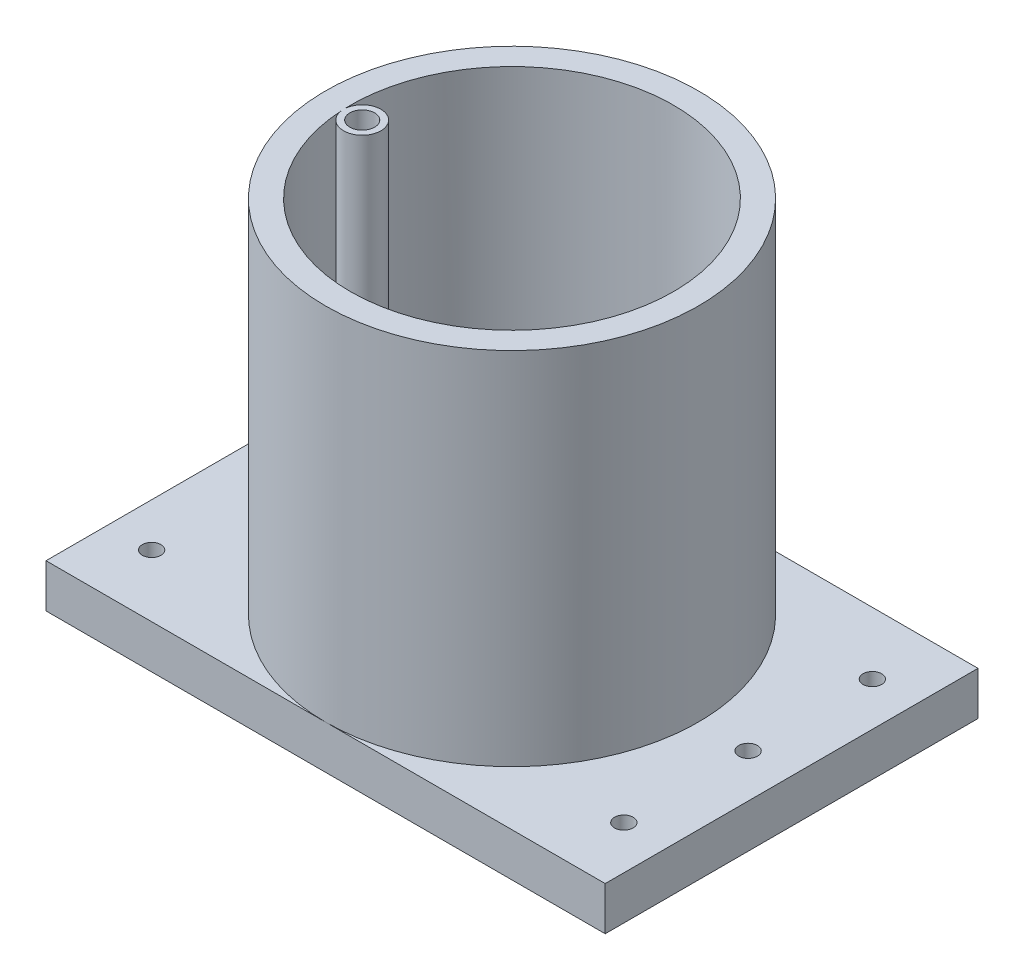
from build123d import *

# Parameters (mm, degrees)
IZIM1_R                     = 30
Y_KSEKLIK_EKSTR_ZYON1_DEPTH = 65
IZIM2_R                     = 26
KES_EKSTR_ZYON1_DEPTH       = 62
Y_KSEKLIK_EKSTR_ZYON4_START = 10
IZIM3_R                     = 3
Y_KSEKLIK_EKSTR_ZYON4_DEPTH = 52
IZIM4_R                     = 2
KES_EKSTR_ZYON2_DEPTH       = 52
IZIM5_W                     = 90
IZIM5_H                     = 60
Y_KSEKLIK_EKSTR_ZYON5_DEPTH = 7
IZIM6_R                     = 1.5
KES_EKSTR_ZYON3_DEPTH       = 10
IZIM7_R                     = 1.5
KES_EKSTR_ZYON4_DEPTH       = 10


with BuildPart() as part:
    # Çizim1 → Yükseklik-Ekstrüzyon1 (new body)
    with BuildSketch(Plane(origin=(0, 0, 0), x_dir=(1, 0, 0), z_dir=(0, 1, 0))):
        Circle(IZIM1_R)
    extrude(amount=Y_KSEKLIK_EKSTR_ZYON1_DEPTH)

    # Çizim2 → Kes-Ekstrüzyon1 (cut)
    with BuildSketch(Plane(origin=(0, 65, 0), x_dir=(1, 0, 0), z_dir=(0, 1, 0))):
        Circle(IZIM2_R)
    extrude(amount=-KES_EKSTR_ZYON1_DEPTH, mode=Mode.SUBTRACT)

    # Çizim3 → Yükseklik-Ekstrüzyon4 (add)
    with BuildSketch(Plane(origin=(0, 3, 0), x_dir=(1, 0, 0), z_dir=(0, 1, 0)).offset(Y_KSEKLIK_EKSTR_ZYON4_START)):
        with Locations((-22.975460117, -1.129367831)):
            Circle(IZIM3_R)
    extrude(amount=Y_KSEKLIK_EKSTR_ZYON4_DEPTH)

    # Çizim4 → Kes-Ekstrüzyon2 (cut)
    with BuildSketch(Plane(origin=(0, 65, 0), x_dir=(1, 0, 0), z_dir=(0, 1, 0))):
        with Locations((-22.975460117, -1.129367831)):
            Circle(IZIM4_R)
    extrude(amount=-KES_EKSTR_ZYON2_DEPTH, mode=Mode.SUBTRACT)

    # Çizim5 → Yükseklik-Ekstrüzyon5 (add)
    with BuildSketch(Plane.XZ):
        Rectangle(IZIM5_W, IZIM5_H)
    extrude(amount=-Y_KSEKLIK_EKSTR_ZYON5_DEPTH)

    # Çizim6 → Kes-Ekstrüzyon3 (cut)
    with BuildSketch(Plane(origin=(0, 7, 0), x_dir=(1, 0, 0), z_dir=(0, 1, 0))):
        with Locations((38, 0)):
            Circle(IZIM6_R)
        with Locations((-38, 0)):
            Circle(IZIM6_R)
    extrude(amount=-KES_EKSTR_ZYON3_DEPTH, mode=Mode.SUBTRACT)

    # Çizim7 → Kes-Ekstrüzyon4 (cut)
    with BuildSketch(Plane(origin=(0, 7, 0), x_dir=(1, 0, 0), z_dir=(0, 1, 0))):
        with Locations((-38, 20)):
            Circle(IZIM7_R)
        with Locations((-38, -20)):
            Circle(IZIM7_R)
        with Locations((38, -20)):
            Circle(IZIM7_R)
        with Locations((38, 20)):
            Circle(IZIM7_R)
    extrude(amount=-KES_EKSTR_ZYON4_DEPTH, mode=Mode.SUBTRACT)


solid = part.part
